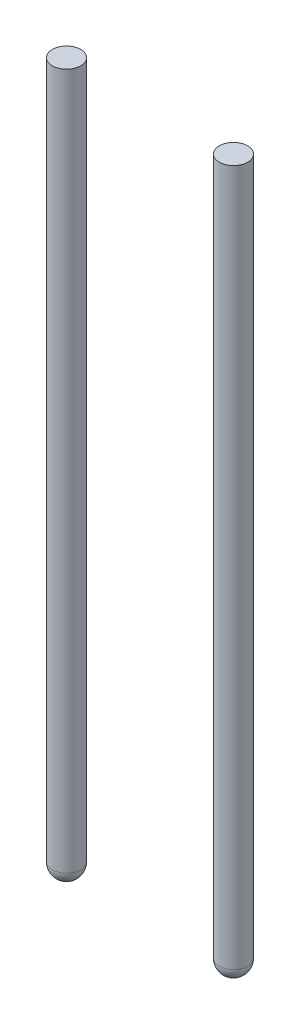
from build123d import *

# Parameters (mm, degrees)
SKETCH3_R             = 0.2
BOSS_EXTRUDE1_DEPTH   = 10
BOSS_EXTRUDE1_2_DEPTH = 10
FILLET3_R             = 0.2
FILLET4_R             = 0.2


with BuildPart() as part:
    # Sketch3 → Boss-Extrude1 (new body)
    with BuildSketch(Plane(origin=(0, 0, 0), x_dir=(1, 0, 0), z_dir=(0, 1, 0))):
        with Locations((1.175, 0)):
            Circle(SKETCH3_R)
    extrude(amount=-BOSS_EXTRUDE1_DEPTH)

    # Fillet3
    fillet3_edges = [part.edges().sort_by_distance(p)[0] for p in [
        (0.975, -10, 0),
    ]]
    fillet(fillet3_edges, radius=FILLET3_R)


with BuildPart() as body_2:
    # Sketch3 → Boss-Extrude1 2 (new body)
    with BuildSketch(Plane(origin=(0, 0, 0), x_dir=(1, 0, 0), z_dir=(0, 1, 0))):
        with Locations((-1.175, 0)):
            Circle(SKETCH3_R)
    extrude(amount=-BOSS_EXTRUDE1_2_DEPTH)

    # Fillet4
    fillet4_edges = [body_2.edges().sort_by_distance(p)[0] for p in [
        (-1.375, -10, 0),
    ]]
    fillet(fillet4_edges, radius=FILLET4_R)


solid = Compound([part.part, body_2.part])
